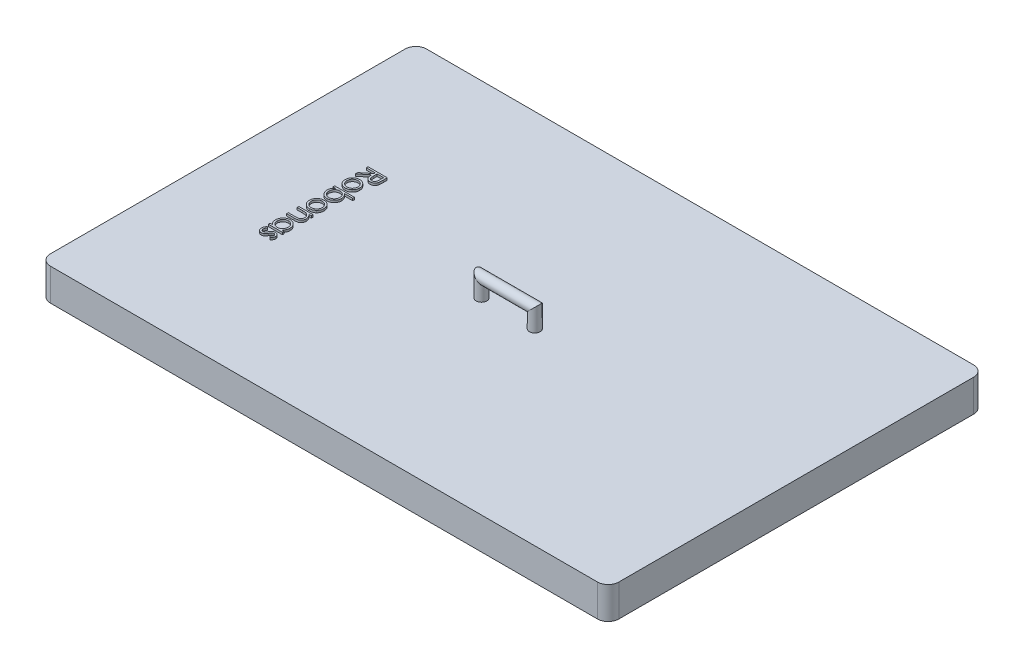
from build123d import *

# Parameters (mm, degrees)
SKETCH1_W           = 266
SKETCH1_H           = 176
BOSS_EXTRUDE2_DEPTH = 15
SKETCH1_4_W         = 256
SKETCH1_4_H         = 169.383458646
CUT_EXTRUDE2_DEPTH  = 10
FILLET1_R           = 5
SKETCH3_R           = 2.5
BOSS_EXTRUDE4_DEPTH = 1


with BuildPart() as part:
    # Sketch1 → Boss-Extrude2 (new body)
    with BuildSketch(Plane(origin=(0, 0, 0), x_dir=(1, 0, 0), z_dir=(0, 1, 0))):
        Rectangle(SKETCH1_W, SKETCH1_H)
    extrude(amount=BOSS_EXTRUDE2_DEPTH)

    # Sketch1_4 → Cut-Extrude2 (cut)
    with BuildSketch(Plane(origin=(0, 0, 0), x_dir=(1, 0, 0), z_dir=(0, 1, 0))):
        Rectangle(SKETCH1_4_W, SKETCH1_4_H)
    extrude(amount=CUT_EXTRUDE2_DEPTH, mode=Mode.SUBTRACT)

    # Fillet1
    fillet1_edges = [part.edges().sort_by_distance(p)[0] for p in [
        (-133, 7.5, -88),
        (133, 7.5, -88),
        (-133, 7.5, 88),
        (133, 7.5, 88),
        (128, 5, -84.691729323),
        (128, 5, 84.691729323),
        (-128, 5, 84.691729323),
        (-128, 5, -84.691729323),
    ]]
    fillet(fillet1_edges, radius=FILLET1_R)

    # Sweep1: sweep along a path in Sketch2
    with BuildLine(Plane.XY) as sweep1_path:
        Line((-14.258436322, 15), (-14.258436322, 23.643706027))
        Line((-14.258436322, 23.643706027), (10.667561874, 23.643706027))
        Line((10.667561874, 23.643706027), (10.667561874, 15))
    # Sketch3 → Sweep1 (sweep)
    with BuildSketch(Plane(origin=(0, 15, 0), x_dir=(1, 0, 0), z_dir=(0, 1, 0))):
        with Locations((10.667561874, 0)):
            Circle(SKETCH3_R)
    sweep(path=sweep1_path.line, transition=Transition.RIGHT)

    # Sketch4 → Boss-Extrude4 (add)
    # profile 1 of 7: a face of its own
    with BuildSketch(Plane(origin=(0, 15, 0), x_dir=(1, 0, 0), z_dir=(0, 1, 0))):
        with BuildLine():
            Line((-84, 25.615384615), (-84, 23.814302885))
            add(Edge.make_bspline(
                [(-84, 23.814302885), (-84.000400078, 23.694111411), (-84.001168273, 23.463330469), (-84.005451663, 23.132713488), (-84.017728578, 22.832300952), (-84.028293507, 22.562249937), (-84.047558499, 22.322565396), (-84.065971591, 22.112512362), (-84.09007529, 21.933058283), (-84.112460664, 21.824426094), (-84.122596154, 21.775240385)],
                knots=[0, 0, 0, 0, 1.410062039, 2.707475311, 3.878576406, 4.937260626, 5.877586885, 6.699081471, 7.410979367, 8, 8, 8, 8], degree=3))
            add(Edge.make_bspline(
                [(-84.122596154, 21.775240385), (-84.138863133, 21.70939362), (-84.171050074, 21.579104781), (-84.239115823, 21.391535723), (-84.317753217, 21.212722526), (-84.410832652, 21.043336224), (-84.516730622, 20.883361104), (-84.636065851, 20.733036691), (-84.769446066, 20.593222433), (-84.9134653, 20.462842527), (-85.069380163, 20.344657339), (-85.234919398, 20.242383522), (-85.409047654, 20.154806965), (-85.592371311, 20.084891967), (-85.783340667, 20.028647494), (-85.983623245, 19.988976389), (-86.192323697, 19.965188625), (-86.334672494, 19.962766572), (-86.406850962, 19.961538462)],
                knots=[0, 0, 0, 0, 1.02737288, 2.032829108, 3.019628684, 3.985738875, 4.958353778, 5.924249254, 6.890702889, 7.883913451, 8.865824512, 9.85161466, 10.829249435, 11.81541824, 12.821369441, 13.843154991, 14.906364023, 16, 16, 16, 16], degree=3))
            add(Edge.make_bspline(
                [(-86.406850962, 19.961538462), (-86.52676994, 19.965315787), (-86.760762927, 19.972686328), (-87.100346123, 20.041409392), (-87.417125695, 20.153972579), (-87.710660795, 20.309108056), (-87.975384276, 20.506575574), (-88.207113118, 20.743886628), (-88.402818683, 21.019829287), (-88.53708995, 21.277919856), (-88.623485838, 21.5060117), (-88.684579464, 21.69434228), (-88.730985975, 21.899935102), (-88.77316301, 22.119840624), (-88.805347476, 22.35575742), (-88.828204564, 22.60721041), (-88.842901845, 22.874828493), (-88.845049181, 23.058273594), (-88.846153846, 23.152644231)],
                knots=[0, 0, 0, 0, 1.260402266, 2.459371274, 3.627181936, 4.786749125, 5.93865593, 7.087644312, 8.261344208, 9.485713728, 10.136162886, 10.825977872, 11.566646758, 12.35154167, 13.181268117, 14.0701832, 15.007234106, 16, 16, 16, 16], degree=3))
            Line((-88.846153846, 23.152644231), (-93, 19.846153846))
            Line((-93, 19.846153846), (-93, 20.844951923))
            Line((-93, 20.844951923), (-88.846153846, 24.151442308))
            Line((-88.846153846, 24.151442308), (-88.846153846, 24.807692308))
            Line((-88.846153846, 24.807692308), (-93, 24.807692308))
            Line((-93, 24.807692308), (-93, 25.615384615))
            Line((-93, 25.615384615), (-84, 25.615384615))
        make_face()
        with BuildLine():
            Line((-84.923076923, 24.807692308), (-87.923076923, 24.807692308))
            Line((-87.923076923, 24.807692308), (-87.935697115, 23.159855769))
            add(Edge.make_bspline(
                [(-87.935697115, 23.159855769), (-87.935731152, 23.082918527), (-87.935797125, 22.933792237), (-87.925527418, 22.718047667), (-87.913844589, 22.517167394), (-87.895974881, 22.331919696), (-87.872944858, 22.162222093), (-87.844137589, 22.008158503), (-87.810573822, 21.869480373), (-87.758632346, 21.70773404), (-87.67629356, 21.527174715), (-87.556701165, 21.330702032), (-87.4053067, 21.163957301), (-87.234940904, 21.020191024), (-87.043774766, 20.909454374), (-86.840293432, 20.828857522), (-86.626253623, 20.778278506), (-86.47924031, 20.772265376), (-86.405048077, 20.769230769)],
                knots=[0, 0, 0, 0, 1.14660753, 2.222451964, 3.218720504, 4.145691244, 4.995719623, 5.770487122, 6.480909919, 7.121111896, 8.299844659, 9.430703709, 10.534634535, 11.641396424, 12.741395289, 13.810956493, 14.895269934, 16, 16, 16, 16], degree=3))
            add(Edge.make_bspline(
                [(-86.405048077, 20.769230769), (-86.332651102, 20.772274704), (-86.189186714, 20.778306672), (-85.979735021, 20.828955521), (-85.780637377, 20.910746007), (-85.595688717, 21.025435198), (-85.426406452, 21.164019494), (-85.283566379, 21.328608954), (-85.163946144, 21.510914648), (-85.088062918, 21.681426648), (-85.041446647, 21.833727621), (-85.008683654, 21.965981609), (-84.982139186, 22.115985304), (-84.961501364, 22.283379214), (-84.942929682, 22.467860496), (-84.930888296, 22.669934296), (-84.92361048, 22.889367263), (-84.923258914, 23.041460017), (-84.923076923, 23.120192308)],
                knots=[0, 0, 0, 0, 1.100801541, 2.181386982, 3.260112282, 4.364594493, 5.481957178, 6.577424609, 7.668452592, 8.790448866, 9.403819393, 10.091598921, 10.863153553, 11.720938239, 12.658472417, 13.685008818, 14.801622349, 16, 16, 16, 16], degree=3))
            Line((-84.923076923, 23.120192308), (-84.923076923, 24.807692308))
        make_face(mode=Mode.SUBTRACT)
    # profile 2 of 7: a face of its own
    with BuildSketch(Plane(origin=(0, 15, 0), x_dir=(1, 0, 0), z_dir=(0, 1, 0))):
        with BuildLine():
            add(Edge.make_bspline(
                [(-86.307692308, 15.054086538), (-86.310312316, 14.930677345), (-86.315449513, 14.688702076), (-86.370625766, 14.334382321), (-86.45429703, 13.996512736), (-86.57207522, 13.673643963), (-86.726604804, 13.368446779), (-86.913477056, 13.078196273), (-87.133956269, 12.803473977), (-87.304605669, 12.638850196), (-87.391225962, 12.555288462)],
                knots=[0, 0, 0, 0, 1.054042676, 2.066720093, 3.05716247, 4.025731183, 4.997454851, 5.974904663, 6.97207755, 8, 8, 8, 8], degree=3))
            add(Edge.make_bspline(
                [(-87.391225962, 12.555288462), (-87.474061925, 12.483334865), (-87.638130748, 12.340820173), (-87.904159467, 12.158079754), (-88.179662583, 12.000652885), (-88.468298566, 11.874490985), (-88.76754772, 11.77501521), (-89.078438606, 11.704389134), (-89.400284641, 11.662379872), (-89.618865939, 11.6567151), (-89.729567308, 11.653846154)],
                knots=[0, 0, 0, 0, 1.025258237, 2.030674902, 3.01204498, 3.988269485, 4.97094183, 5.956517959, 6.965070386, 8, 8, 8, 8], degree=3))
            add(Edge.make_bspline(
                [(-89.729567308, 11.653846154), (-89.840910313, 11.656369593), (-90.060929285, 11.661356025), (-90.38497908, 11.708525326), (-90.699194348, 11.781890971), (-91.002259526, 11.886887142), (-91.295101212, 12.021522221), (-91.576439558, 12.185812785), (-91.846832662, 12.380910367), (-92.103972868, 12.602066842), (-92.340999224, 12.846473491), (-92.547457975, 13.111674427), (-92.725083307, 13.392650259), (-92.86616721, 13.693236584), (-92.979890661, 14.009154651), (-93.0583103, 14.342413897), (-93.106148408, 14.692717027), (-93.112262572, 14.931935629), (-93.115384615, 15.054086538)],
                knots=[0, 0, 0, 0, 0.998669827, 1.973418153, 2.932281609, 3.89081133, 4.846438734, 5.82045571, 6.809776312, 7.834649874, 8.860672198, 9.859676908, 10.845817165, 11.837296335, 12.833502054, 13.853824644, 14.904110009, 16, 16, 16, 16], degree=3))
            add(Edge.make_bspline(
                [(-93.115384615, 15.054086538), (-93.112236741, 15.17683004), (-93.106071469, 15.417229389), (-93.058666147, 15.768851558), (-92.97905278, 16.10351393), (-92.867575081, 16.420926363), (-92.723924488, 16.721511469), (-92.548149099, 17.003524808), (-92.340894678, 17.268850834), (-92.104001195, 17.513334109), (-91.846825363, 17.73447004), (-91.576441452, 17.929572923), (-91.295100718, 18.093862109), (-91.002259657, 18.228497549), (-90.699194313, 18.333493624), (-90.38497909, 18.406859295), (-90.060929283, 18.454028589), (-89.840910312, 18.459015022), (-89.729567308, 18.461538462)],
                knots=[0, 0, 0, 0, 1.099861214, 2.154133753, 3.1731438, 4.178222029, 5.163564916, 6.153006591, 7.15072618, 8.175428628, 9.198983792, 10.187031731, 11.15979573, 12.114193814, 13.071490482, 14.029120454, 15.002614863, 16, 16, 16, 16], degree=3))
            add(Edge.make_bspline(
                [(-89.729567308, 18.461538462), (-89.619467618, 18.458649949), (-89.401489155, 18.452931191), (-89.080248142, 18.410964168), (-88.769883427, 18.340613594), (-88.471789346, 18.241018575), (-88.184418225, 18.113693798), (-87.908234374, 17.958479058), (-87.643408601, 17.773874574), (-87.479551824, 17.631926699), (-87.396634615, 17.560096154)],
                knots=[0, 0, 0, 0, 1.031353054, 2.041901799, 3.029428768, 4.008703097, 4.981709435, 5.96992636, 6.972712378, 8, 8, 8, 8], degree=3))
            add(Edge.make_bspline(
                [(-87.396634615, 17.560096154), (-87.309277722, 17.476653482), (-87.137475019, 17.312548786), (-86.917430822, 17.036558333), (-86.728039083, 16.747556385), (-86.573587268, 16.440390574), (-86.454510729, 16.116624041), (-86.370235247, 15.776243341), (-86.315693572, 15.420633933), (-86.310385976, 15.17748666), (-86.307692308, 15.054086538)],
                knots=[0, 0, 0, 0, 1.027951202, 2.021646915, 2.998468564, 3.9668038, 4.943370589, 5.93035926, 6.949632805, 8, 8, 8, 8], degree=3))
        make_face()
        with BuildLine():
            add(Edge.make_bspline(
                [(-87.115384615, 15.057692308), (-87.117865128, 15.144960353), (-87.122762119, 15.317243633), (-87.160004511, 15.570838265), (-87.219019534, 15.814964861), (-87.302832154, 16.050117738), (-87.411186056, 16.275387406), (-87.543521406, 16.491021727), (-87.700543034, 16.696441367), (-87.879129987, 16.890068263), (-88.073106737, 17.069855859), (-88.281691003, 17.225206495), (-88.49889891, 17.357547932), (-88.725857929, 17.4676806), (-88.964717468, 17.549735125), (-89.212812329, 17.609320871), (-89.470637197, 17.646530608), (-89.645908454, 17.651381221), (-89.734975962, 17.653846154)],
                knots=[0, 0, 0, 0, 1.021589593, 2.016807015, 2.994807536, 3.958602519, 4.934347097, 5.916793557, 6.916107818, 7.957073844, 8.998039869, 10.008589932, 10.997041759, 11.972786337, 12.956492182, 13.948170289, 14.957322718, 16, 16, 16, 16], degree=3))
            add(Edge.make_bspline(
                [(-89.734975962, 17.653846154), (-89.850057688, 17.649725225), (-90.078473396, 17.641545951), (-90.414770075, 17.574695016), (-90.738231289, 17.463652497), (-91.044962481, 17.310532301), (-91.329253269, 17.121960174), (-91.584888887, 16.901463746), (-91.802010999, 16.645994577), (-91.984614351, 16.364251882), (-92.12841432, 16.060228314), (-92.231538019, 15.739020958), (-92.297672127, 15.403554503), (-92.304323016, 15.173988685), (-92.307692308, 15.057692308)],
                knots=[0, 0, 0, 0, 1.016977094, 2.018509362, 3.018404954, 4.033172147, 5.041280572, 6.028085189, 7.007940189, 7.995502847, 8.989109012, 9.972200833, 10.97273166, 12, 12, 12, 12], degree=3))
            add(Edge.make_bspline(
                [(-92.307692308, 15.057692308), (-92.304342533, 14.941389241), (-92.29773017, 14.711810218), (-92.231202961, 14.375877005), (-92.128862738, 14.053789322), (-91.984451938, 13.749449647), (-91.802701192, 13.467578647), (-91.583651962, 13.213933703), (-91.329925288, 12.991538389), (-91.04533943, 12.802779541), (-90.737754438, 12.652126536), (-90.414829675, 12.540561816), (-90.078458217, 12.473871208), (-89.850052603, 12.465670294), (-89.734975962, 12.461538462)],
                knots=[0, 0, 0, 0, 1.027082318, 2.027431966, 3.015401697, 4.008827937, 4.996211763, 5.971861488, 6.96198607, 7.969911943, 8.982141629, 9.981856156, 10.983207064, 12, 12, 12, 12], degree=3))
            add(Edge.make_bspline(
                [(-89.734975962, 12.461538462), (-89.645901342, 12.463985054), (-89.47061609, 12.468799576), (-89.212893014, 12.506271823), (-88.96422677, 12.564931961), (-88.726820518, 12.650579676), (-88.49779043, 12.756932527), (-88.282343243, 12.892493322), (-88.072974138, 13.047120367), (-87.879246904, 13.227237869), (-87.699890518, 13.420842965), (-87.544093401, 13.627805831), (-87.411110485, 13.843540298), (-87.30281881, 14.068881158), (-87.219342131, 14.303501896), (-87.159747432, 14.546887309), (-87.122897909, 14.799358904), (-87.117905064, 14.971030421), (-87.115384615, 15.057692308)],
                knots=[0, 0, 0, 0, 1.043020522, 2.052505155, 3.044509714, 4.030878336, 5.003918577, 5.996372628, 7.007255355, 8.048564058, 9.08987276, 10.095126797, 11.077896669, 12.053962454, 13.01807471, 13.98956039, 14.985105429, 16, 16, 16, 16], degree=3))
        make_face(mode=Mode.SUBTRACT)
    # profile 3 of 7: a face of its own
    with BuildSketch(Plane(origin=(0, 15, 0), x_dir=(1, 0, 0), z_dir=(0, 1, 0))):
        with BuildLine():
            Line((-93, 10.038461538), (-83.769230769, 10.038461538))
            Line((-83.769230769, 10.038461538), (-83.769230769, 9.230769231))
            Line((-83.769230769, 9.230769231), (-87.616586538, 9.230769231))
            add(Edge.make_bspline(
                [(-87.616586538, 9.230769231), (-87.511565591, 9.14055883), (-87.306035054, 8.964013173), (-87.041638365, 8.664576056), (-86.812532085, 8.353748728), (-86.628333438, 8.023877242), (-86.484150291, 7.677854951), (-86.381749418, 7.316051007), (-86.318088663, 6.937345855), (-86.311198001, 6.679340003), (-86.307692308, 6.548076923)],
                knots=[0, 0, 0, 0, 1.073845349, 2.101561798, 3.093746447, 4.06731023, 5.027507813, 5.99794647, 6.981435071, 8, 8, 8, 8], degree=3))
            add(Edge.make_bspline(
                [(-86.307692308, 6.548076923), (-86.310874268, 6.431932707), (-86.317165545, 6.202295798), (-86.365186826, 5.864752417), (-86.442375726, 5.540354965), (-86.551412171, 5.229033099), (-86.692883108, 4.930954836), (-86.864644861, 4.645078234), (-87.068295232, 4.372771858), (-87.301299405, 4.118090849), (-87.554177383, 3.883262376), (-87.824755781, 3.67802318), (-88.108202711, 3.503682347), (-88.40638236, 3.363434969), (-88.715630694, 3.24899862), (-89.040375561, 3.17339941), (-89.377722514, 3.124564577), (-89.607397299, 3.11847859), (-89.724158654, 3.115384615)],
                knots=[0, 0, 0, 0, 1.034424137, 2.045232812, 3.030843571, 4.001080581, 4.978206309, 5.965255608, 6.967506581, 8.002193933, 9.036548792, 10.037741014, 11.022988172, 11.995276286, 12.96911093, 13.954721688, 14.960227752, 16, 16, 16, 16], degree=3))
            add(Edge.make_bspline(
                [(-89.724158654, 3.115384615), (-89.839101557, 3.118564034), (-90.065750859, 3.124833346), (-90.399282004, 3.17271671), (-90.720295801, 3.251778533), (-91.027962749, 3.364821576), (-91.32372824, 3.506931419), (-91.604220708, 3.684646128), (-91.874320931, 3.889874412), (-92.125353126, 4.127297365), (-92.357381869, 4.38421793), (-92.558996951, 4.659140269), (-92.733126688, 4.945139496), (-92.871097839, 5.246673213), (-92.982700208, 5.559276748), (-93.060145699, 5.886299171), (-93.105333555, 6.225890329), (-93.11200787, 6.456596042), (-93.115384615, 6.573317308)],
                knots=[0, 0, 0, 0, 1.024244038, 2.01964794, 2.996620209, 3.965911562, 4.936179293, 5.91563013, 6.920572822, 7.955171681, 8.990768464, 10.002129126, 10.989675881, 11.969873457, 12.952483066, 13.943799762, 14.959703725, 16, 16, 16, 16], degree=3))
            add(Edge.make_bspline(
                [(-93.115384615, 6.573317308), (-93.111685864, 6.706943972), (-93.104433259, 6.968962561), (-93.044132873, 7.352211302), (-92.942075532, 7.7145635), (-92.803561892, 8.060093369), (-92.616958176, 8.384927793), (-92.386781385, 8.692266027), (-92.10612044, 8.976983158), (-91.892587031, 9.144724562), (-91.783052885, 9.230769231)],
                knots=[0, 0, 0, 0, 1.035884751, 2.031189381, 2.999123778, 3.950239786, 4.910390163, 5.895605504, 6.920529319, 8, 8, 8, 8], degree=3))
            Line((-91.783052885, 9.230769231), (-93, 9.230769231))
            Line((-93, 9.230769231), (-93, 10.038461538))
        make_face()
        with BuildLine():
            add(Edge.make_bspline(
                [(-92.307692308, 6.580528846), (-92.303491502, 6.462463439), (-92.29519978, 6.229421106), (-92.230468265, 5.887307473), (-92.122763785, 5.559931944), (-91.97547212, 5.248920902), (-91.790238118, 4.959228033), (-91.566275507, 4.7002075), (-91.309682789, 4.470641403), (-91.022814178, 4.275838035), (-90.713961589, 4.118571955), (-90.391528611, 4.007794306), (-90.061005568, 3.934142726), (-89.836930175, 3.926781595), (-89.724158654, 3.923076923)],
                knots=[0, 0, 0, 0, 1.031861621, 2.036730714, 3.032102247, 4.038124785, 5.038035477, 6.029195352, 7.02284546, 8.040167683, 9.05302878, 10.043491941, 11.015338596, 12, 12, 12, 12], degree=3))
            add(Edge.make_bspline(
                [(-89.724158654, 3.923076923), (-89.611474992, 3.927886568), (-89.38655753, 3.937486655), (-89.053598118, 4.005934516), (-88.729956016, 4.121664762), (-88.418136822, 4.279110017), (-88.128630504, 4.476310745), (-87.867035107, 4.704889798), (-87.64197827, 4.967008534), (-87.45426317, 5.25708886), (-87.301117069, 5.566133526), (-87.196085154, 5.891392555), (-87.127330298, 6.22608555), (-87.11938676, 6.453388154), (-87.115384615, 6.567908654)],
                knots=[0, 0, 0, 0, 0.984698701, 1.96546623, 2.957354799, 3.98164001, 5.010280354, 6.011473015, 7.009725998, 8.019440419, 9.024964737, 10.015029379, 10.999924227, 12, 12, 12, 12], degree=3))
            add(Edge.make_bspline(
                [(-87.115384615, 6.567908654), (-87.119384624, 6.684824927), (-87.127323829, 6.916880004), (-87.196204475, 7.25931516), (-87.301764451, 7.593753649), (-87.453267947, 7.913388158), (-87.638823242, 8.211159027), (-87.856018982, 8.477775244), (-88.106158849, 8.705448988), (-88.384365932, 8.894973668), (-88.686237005, 9.04436577), (-89.006900708, 9.154717045), (-89.347247902, 9.218277087), (-89.580268452, 9.226554515), (-89.698918269, 9.230769231)],
                knots=[0, 0, 0, 0, 1.0169775, 2.018493981, 3.029491472, 4.064042901, 5.08895728, 6.077764832, 7.048099865, 8.023317454, 8.999054219, 9.971953187, 10.967355531, 12, 12, 12, 12], degree=3))
            add(Edge.make_bspline(
                [(-89.698918269, 9.230769231), (-89.78978698, 9.228301546), (-89.968645359, 9.223444361), (-90.23125892, 9.186337141), (-90.48257442, 9.127310338), (-90.722854875, 9.044133924), (-90.950776258, 8.93487266), (-91.16795834, 8.803085007), (-91.373335029, 8.646500316), (-91.563835212, 8.467460516), (-91.738064869, 8.272292486), (-91.891039262, 8.063841521), (-92.018895683, 7.843445365), (-92.124292367, 7.612128556), (-92.208310503, 7.370412697), (-92.264325741, 7.116166409), (-92.302797937, 6.852136788), (-92.306043673, 6.672018076), (-92.307692308, 6.580528846)],
                knots=[0, 0, 0, 0, 1.050410851, 2.067540964, 3.060285716, 4.031641603, 5.001405429, 5.977447716, 6.964216063, 7.981915705, 8.995836261, 9.985438752, 10.966317358, 11.93650433, 12.920994585, 13.918930257, 14.942944538, 16, 16, 16, 16], degree=3))
        make_face(mode=Mode.SUBTRACT)
    # profile 4 of 7: a face of its own
    with BuildSketch(Plane(origin=(0, 15, 0), x_dir=(1, 0, 0), z_dir=(0, 1, 0))):
        with BuildLine():
            add(Edge.make_bspline(
                [(-86.307692308, -1.676682692), (-86.310312316, -1.800091886), (-86.315449513, -2.042067155), (-86.370625766, -2.39638691), (-86.45429703, -2.734256495), (-86.57207522, -3.057125267), (-86.726604804, -3.362322452), (-86.913477056, -3.652572958), (-87.133956269, -3.927295254), (-87.304605669, -4.091919034), (-87.391225962, -4.175480769)],
                knots=[0, 0, 0, 0, 1.054042676, 2.066720093, 3.05716247, 4.025731183, 4.997454851, 5.974904663, 6.97207755, 8, 8, 8, 8], degree=3))
            add(Edge.make_bspline(
                [(-87.391225962, -4.175480769), (-87.474061925, -4.247434365), (-87.638130748, -4.389949057), (-87.904159467, -4.572689477), (-88.179662583, -4.730116346), (-88.468298566, -4.856278246), (-88.76754772, -4.955754021), (-89.078438606, -5.026380097), (-89.400284641, -5.068389358), (-89.618865939, -5.074054131), (-89.729567308, -5.076923077)],
                knots=[0, 0, 0, 0, 1.025258237, 2.030674902, 3.01204498, 3.988269485, 4.97094183, 5.956517959, 6.965070386, 8, 8, 8, 8], degree=3))
            add(Edge.make_bspline(
                [(-89.729567308, -5.076923077), (-89.840910313, -5.074399638), (-90.060929285, -5.069413206), (-90.38497908, -5.022243905), (-90.699194348, -4.94887826), (-91.002259526, -4.843882089), (-91.295101212, -4.709247009), (-91.576439558, -4.544956446), (-91.846832662, -4.349858864), (-92.103972868, -4.128702389), (-92.340999224, -3.884295739), (-92.547457975, -3.619094803), (-92.725083307, -3.338118972), (-92.86616721, -3.037532647), (-92.979890661, -2.72161458), (-93.0583103, -2.388355334), (-93.106148408, -2.038052203), (-93.112262572, -1.798833602), (-93.115384615, -1.676682692)],
                knots=[0, 0, 0, 0, 0.998669827, 1.973418153, 2.932281609, 3.89081133, 4.846438734, 5.82045571, 6.809776312, 7.834649874, 8.860672198, 9.859676908, 10.845817165, 11.837296335, 12.833502054, 13.853824644, 14.904110009, 16, 16, 16, 16], degree=3))
            add(Edge.make_bspline(
                [(-93.115384615, -1.676682692), (-93.112236741, -1.553939191), (-93.106071469, -1.313539842), (-93.058666147, -0.961917672), (-92.97905278, -0.627255301), (-92.867575081, -0.309842868), (-92.723924488, -0.009257762), (-92.548149099, 0.272755577), (-92.340894678, 0.538081603), (-92.104001195, 0.782564879), (-91.846825363, 1.003700809), (-91.576441452, 1.198803692), (-91.295100718, 1.363092879), (-91.002259657, 1.497728319), (-90.699194313, 1.602724393), (-90.38497909, 1.676090064), (-90.060929283, 1.723259358), (-89.840910312, 1.728245792), (-89.729567308, 1.730769231)],
                knots=[0, 0, 0, 0, 1.099861214, 2.154133753, 3.1731438, 4.178222029, 5.163564916, 6.153006591, 7.15072618, 8.175428628, 9.198983792, 10.187031731, 11.15979573, 12.114193814, 13.071490482, 14.029120454, 15.002614863, 16, 16, 16, 16], degree=3))
            add(Edge.make_bspline(
                [(-89.729567308, 1.730769231), (-89.619467618, 1.727880718), (-89.401489155, 1.72216196), (-89.080248142, 1.680194937), (-88.769883427, 1.609844363), (-88.471789346, 1.510249344), (-88.184418225, 1.382924567), (-87.908234374, 1.227709827), (-87.643408601, 1.043105343), (-87.479551824, 0.901157468), (-87.396634615, 0.829326923)],
                knots=[0, 0, 0, 0, 1.031353054, 2.041901799, 3.029428768, 4.008703097, 4.981709435, 5.96992636, 6.972712378, 8, 8, 8, 8], degree=3))
            add(Edge.make_bspline(
                [(-87.396634615, 0.829326923), (-87.309277722, 0.745884252), (-87.137475019, 0.581779556), (-86.917430822, 0.305789102), (-86.728039083, 0.016787154), (-86.573587268, -0.290378657), (-86.454510729, -0.61414519), (-86.370235247, -0.954525889), (-86.315693572, -1.310135297), (-86.310385976, -1.553282571), (-86.307692308, -1.676682692)],
                knots=[0, 0, 0, 0, 1.027951202, 2.021646915, 2.998468564, 3.9668038, 4.943370589, 5.93035926, 6.949632805, 8, 8, 8, 8], degree=3))
        make_face()
        with BuildLine():
            add(Edge.make_bspline(
                [(-87.115384615, -1.673076923), (-87.117865128, -1.585808878), (-87.122762119, -1.413525597), (-87.160004511, -1.159930966), (-87.219019534, -0.91580437), (-87.302832154, -0.680651493), (-87.411186056, -0.455381824), (-87.543521406, -0.239747504), (-87.700543034, -0.034327863), (-87.879129987, 0.159299032), (-88.073106737, 0.339086628), (-88.281691003, 0.494437264), (-88.49889891, 0.626778701), (-88.725857929, 0.73691137), (-88.964717468, 0.818965895), (-89.212812329, 0.87855164), (-89.470637197, 0.915761377), (-89.645908454, 0.92061199), (-89.734975962, 0.923076923)],
                knots=[0, 0, 0, 0, 1.021589593, 2.016807015, 2.994807536, 3.958602519, 4.934347097, 5.916793557, 6.916107818, 7.957073844, 8.998039869, 10.008589932, 10.997041759, 11.972786337, 12.956492182, 13.948170289, 14.957322718, 16, 16, 16, 16], degree=3))
            add(Edge.make_bspline(
                [(-89.734975962, 0.923076923), (-89.850057688, 0.918955994), (-90.078473396, 0.91077672), (-90.414770075, 0.843925785), (-90.738231289, 0.732883266), (-91.044962481, 0.57976307), (-91.329253269, 0.391190944), (-91.584888887, 0.170694515), (-91.802010999, -0.084774654), (-91.984614351, -0.366517349), (-92.12841432, -0.670540917), (-92.231538019, -0.991748273), (-92.297672127, -1.327214728), (-92.304323016, -1.556780546), (-92.307692308, -1.673076923)],
                knots=[0, 0, 0, 0, 1.016977094, 2.018509362, 3.018404954, 4.033172147, 5.041280572, 6.028085189, 7.007940189, 7.995502847, 8.989109012, 9.972200833, 10.97273166, 12, 12, 12, 12], degree=3))
            add(Edge.make_bspline(
                [(-92.307692308, -1.673076923), (-92.304342533, -1.78937999), (-92.29773017, -2.018959013), (-92.231202961, -2.354892226), (-92.128862738, -2.676979909), (-91.984451938, -2.981319583), (-91.802701192, -3.263190584), (-91.583651962, -3.516835528), (-91.329925288, -3.739230842), (-91.04533943, -3.92798969), (-90.737754438, -4.078642695), (-90.414829675, -4.190207415), (-90.078458217, -4.256898023), (-89.850052603, -4.265098937), (-89.734975962, -4.269230769)],
                knots=[0, 0, 0, 0, 1.027082318, 2.027431966, 3.015401697, 4.008827937, 4.996211763, 5.971861488, 6.96198607, 7.969911943, 8.982141629, 9.981856156, 10.983207064, 12, 12, 12, 12], degree=3))
            add(Edge.make_bspline(
                [(-89.734975962, -4.269230769), (-89.645901342, -4.266784176), (-89.47061609, -4.261969655), (-89.212893014, -4.224497408), (-88.96422677, -4.16583727), (-88.726820518, -4.080189555), (-88.49779043, -3.973836704), (-88.282343243, -3.838275908), (-88.072974138, -3.683648864), (-87.879246904, -3.503531362), (-87.699890518, -3.309926266), (-87.544093401, -3.1029634), (-87.411110485, -2.887228932), (-87.30281881, -2.661888073), (-87.219342131, -2.427267335), (-87.159747432, -2.183881921), (-87.122897909, -1.931410327), (-87.117905064, -1.75973881), (-87.115384615, -1.673076923)],
                knots=[0, 0, 0, 0, 1.043020522, 2.052505155, 3.044509714, 4.030878336, 5.003918577, 5.996372628, 7.007255355, 8.048564058, 9.08987276, 10.095126797, 11.077896669, 12.053962454, 13.01807471, 13.98956039, 14.985105429, 16, 16, 16, 16], degree=3))
        make_face(mode=Mode.SUBTRACT)
    # profile 5 of 7: a face of its own
    with BuildSketch(Plane(origin=(0, 15, 0), x_dir=(1, 0, 0), z_dir=(0, 1, 0))):
        with BuildLine():
            Line((-86.423076923, -6.692307692), (-86.423076923, -7.5))
            Line((-86.423076923, -7.5), (-87.609375, -7.5))
            add(Edge.make_bspline(
                [(-87.609375, -7.5), (-87.501779427, -7.586239633), (-87.292986464, -7.75359065), (-87.018562129, -8.032293221), (-86.792417265, -8.326834679), (-86.612150366, -8.63541126), (-86.476259042, -8.958441857), (-86.378118076, -9.293957409), (-86.319271374, -9.643966653), (-86.31158221, -9.88198949), (-86.307692308, -10.002403846)],
                knots=[0, 0, 0, 0, 1.12780773, 2.188550248, 3.19190651, 4.159438251, 5.104880172, 6.052711206, 7.014878035, 8, 8, 8, 8], degree=3))
            add(Edge.make_bspline(
                [(-86.307692308, -10.002403846), (-86.31218663, -10.124107902), (-86.320983102, -10.362312097), (-86.390360482, -10.709187754), (-86.509549089, -11.033446574), (-86.671166142, -11.334378224), (-86.873229581, -11.605067369), (-87.109897835, -11.84064041), (-87.380037022, -12.037143557), (-87.631419505, -12.168697028), (-87.854319996, -12.255434036), (-88.045243386, -12.310028215), (-88.257946233, -12.356394592), (-88.491791188, -12.39659021), (-88.748415015, -12.423788591), (-89.026766251, -12.44524017), (-89.326754578, -12.460613963), (-89.534234478, -12.461223923), (-89.641225962, -12.461538462)],
                knots=[0, 0, 0, 0, 1.235764744, 2.418689688, 3.575570385, 4.733739044, 5.876600945, 6.994686206, 8.113221397, 9.257403329, 9.866223892, 10.540462211, 11.272173464, 12.077110251, 12.949508505, 13.892531187, 14.913238277, 16, 16, 16, 16], degree=3))
            Line((-89.641225962, -12.461538462), (-93, -12.461538462))
            Line((-93, -12.461538462), (-93, -11.653846154))
            Line((-93, -11.653846154), (-89.90625, -11.653846154))
            add(Edge.make_bspline(
                [(-89.90625, -11.653846154), (-89.81670657, -11.653349333), (-89.645425228, -11.652399), (-89.400190597, -11.649401623), (-89.177796538, -11.642176406), (-88.978774736, -11.632023601), (-88.8033163, -11.617163237), (-88.651063874, -11.601676471), (-88.522210765, -11.582737959), (-88.44464341, -11.565861896), (-88.409855769, -11.558293269)],
                knots=[0, 0, 0, 0, 1.430800155, 2.736877192, 3.918605307, 4.986035426, 5.920637409, 6.731861385, 7.431261377, 8, 8, 8, 8], degree=3))
            add(Edge.make_bspline(
                [(-88.409855769, -11.558293269), (-88.307741294, -11.530970474), (-88.111202522, -11.478382546), (-87.844611329, -11.348438018), (-87.617815989, -11.184344411), (-87.432218705, -10.984035655), (-87.287779411, -10.749446604), (-87.18756067, -10.481228236), (-87.124878835, -10.181968875), (-87.118637638, -9.971486176), (-87.115384615, -9.861778846)],
                knots=[0, 0, 0, 0, 1.084156227, 2.086665306, 3.027808233, 3.945421172, 4.874247719, 5.839848303, 6.874090471, 8, 8, 8, 8], degree=3))
            add(Edge.make_bspline(
                [(-87.115384615, -9.861778846), (-87.116608172, -9.796804575), (-87.119029558, -9.668222171), (-87.143339541, -9.477554133), (-87.183064972, -9.292593837), (-87.236818931, -9.1115591), (-87.309966738, -8.938290147), (-87.39463632, -8.767723606), (-87.498317192, -8.60474078), (-87.614493028, -8.446259097), (-87.74396794, -8.298989976), (-87.878587907, -8.159996659), (-88.024020466, -8.037876023), (-88.175115725, -7.927024027), (-88.334910949, -7.831450252), (-88.501697475, -7.747992094), (-88.675739267, -7.677187991), (-88.796532016, -7.64200366), (-88.856971154, -7.624399038)],
                knots=[0, 0, 0, 0, 1.02388931, 2.02625049, 3.024079426, 4.004119353, 4.998163158, 5.985366248, 7.002659681, 8.039138713, 9.080111048, 10.09169763, 11.086418407, 12.069932368, 13.043171485, 14.017654831, 15.008125612, 16, 16, 16, 16], degree=3))
            add(Edge.make_bspline(
                [(-88.856971154, -7.624399038), (-88.901341676, -7.614268514), (-88.997933982, -7.592214891), (-89.156448203, -7.568395285), (-89.33981671, -7.546775806), (-89.547825525, -7.528680769), (-89.781202918, -7.517609698), (-90.038952216, -7.505538392), (-90.322101186, -7.501143664), (-90.519231253, -7.500391897), (-90.621995192, -7.5)],
                knots=[0, 0, 0, 0, 0.615963638, 1.340920617, 2.168419149, 3.115676021, 4.16674242, 5.331190069, 6.6087489, 8, 8, 8, 8], degree=3))
            Line((-90.621995192, -7.5), (-93, -7.5))
            Line((-93, -7.5), (-93, -6.692307692))
            Line((-93, -6.692307692), (-86.423076923, -6.692307692))
        make_face()
    # profile 6 of 7: a face of its own
    with BuildSketch(Plane(origin=(0, 15, 0), x_dir=(1, 0, 0), z_dir=(0, 1, 0))):
        with BuildLine():
            Line((-86.423076923, -21), (-93, -21))
            Line((-93, -21), (-93, -20.192307692))
            Line((-93, -20.192307692), (-91.862379808, -20.192307692))
            add(Edge.make_bspline(
                [(-91.862379808, -20.192307692), (-91.965366553, -20.101249847), (-92.166346482, -19.923549316), (-92.428127588, -19.626806496), (-92.646290556, -19.313567622), (-92.820856663, -18.982773465), (-92.95298278, -18.63541375), (-93.045897696, -18.272479061), (-93.106382769, -17.8944531), (-93.11235708, -17.636652431), (-93.115384615, -17.506009615)],
                knots=[0, 0, 0, 0, 1.074295371, 2.096500925, 3.086030275, 4.053105238, 5.014108356, 5.985331429, 6.979048527, 8, 8, 8, 8], degree=3))
            add(Edge.make_bspline(
                [(-93.115384615, -17.506009615), (-93.11223161, -17.389863133), (-93.106013744, -17.160817126), (-93.057760295, -16.823889752), (-92.980309339, -16.499635781), (-92.872461929, -16.18784856), (-92.730144207, -15.890640702), (-92.557920105, -15.606337521), (-92.354837468, -15.334275502), (-92.12176669, -15.079628697), (-91.868886425, -14.844838033), (-91.598381295, -14.639419916), (-91.313966682, -14.465321373), (-91.015722522, -14.322243552), (-90.703866831, -14.211522432), (-90.378613549, -14.134490491), (-90.040503879, -14.086289041), (-89.810258409, -14.080074325), (-89.693509615, -14.076923077)],
                knots=[0, 0, 0, 0, 1.034036272, 2.039165313, 3.024406509, 3.999331371, 4.971254918, 5.953351348, 6.95522652, 7.989525907, 9.023492927, 10.024309745, 11.009187477, 11.988246066, 12.964946762, 13.950187958, 14.960617622, 16, 16, 16, 16], degree=3))
            add(Edge.make_bspline(
                [(-89.693509615, -14.076923077), (-89.57917389, -14.080144219), (-89.35313833, -14.086512242), (-89.020714435, -14.13397472), (-88.700498621, -14.213726872), (-88.393677087, -14.325862164), (-88.099014162, -14.469016069), (-87.818815292, -14.646108712), (-87.548794224, -14.851452807), (-87.297610055, -15.08875279), (-87.066430209, -15.345685143), (-86.86285404, -15.619269321), (-86.691071506, -15.906094004), (-86.551429007, -16.206734315), (-86.440460576, -16.519061455), (-86.363104894, -16.845448006), (-86.317632137, -17.184409694), (-86.31103742, -17.414525684), (-86.307692308, -17.53125)],
                knots=[0, 0, 0, 0, 1.02050356, 2.017480486, 2.990790918, 3.96161403, 4.928589988, 5.909588639, 6.91611943, 7.952353252, 8.989586576, 9.99823133, 10.991940466, 11.968822692, 12.952985106, 13.945868367, 14.958059758, 16, 16, 16, 16], degree=3))
            add(Edge.make_bspline(
                [(-86.307692308, -17.53125), (-86.311371382, -17.665483434), (-86.318585872, -17.928708863), (-86.379263405, -18.31422357), (-86.480513657, -18.679258838), (-86.619668516, -19.025918778), (-86.803214933, -19.352858613), (-87.036841063, -19.656054583), (-87.315209721, -19.941610515), (-87.529647491, -20.107117208), (-87.640024038, -20.192307692)],
                knots=[0, 0, 0, 0, 1.03879612, 2.037030165, 3.012306674, 3.966139504, 4.922386257, 5.905048148, 6.921675258, 8, 8, 8, 8], degree=3))
            Line((-87.640024038, -20.192307692), (-86.423076923, -20.192307692))
            Line((-86.423076923, -20.192307692), (-86.423076923, -21))
        make_face()
        with BuildLine():
            add(Edge.make_bspline(
                [(-87.115384615, -17.542067308), (-87.119585353, -17.424001796), (-87.127876941, -17.190959256), (-87.192609439, -16.848847136), (-87.300310225, -16.521465923), (-87.447615783, -16.210476258), (-87.632798266, -15.920704122), (-87.856951424, -15.66197676), (-88.112947113, -15.431198768), (-88.402937611, -15.240395503), (-88.710276168, -15.07952937), (-89.033988106, -14.969215141), (-89.365092714, -14.895808473), (-89.589754066, -14.888356129), (-89.702524038, -14.884615385)],
                knots=[0, 0, 0, 0, 1.031093775, 2.03521511, 3.029845951, 4.035119871, 5.034286494, 6.024708811, 7.017619509, 8.03559408, 9.050082311, 10.039808432, 11.016071318, 12, 12, 12, 12], degree=3))
            add(Edge.make_bspline(
                [(-89.702524038, -14.884615385), (-89.814597878, -14.88945503), (-90.038306264, -14.899115351), (-90.370394629, -14.967280194), (-90.69280339, -15.085386759), (-91.004399259, -15.242581106), (-91.294984998, -15.437664235), (-91.555986654, -15.666526921), (-91.781038762, -15.92855353), (-91.969407446, -16.218954206), (-92.121035282, -16.528644657), (-92.227954644, -16.854474592), (-92.295468464, -17.190719078), (-92.303603987, -17.419757676), (-92.307692308, -17.534855769)],
                knots=[0, 0, 0, 0, 0.979154363, 1.954470772, 2.947816011, 3.971783346, 4.997163654, 5.998045606, 6.995988793, 8.00538986, 9.015323546, 10.000094788, 10.994993517, 12, 12, 12, 12], degree=3))
            add(Edge.make_bspline(
                [(-92.307692308, -17.534855769), (-92.303487754, -17.651732091), (-92.295146583, -17.883596301), (-92.229331508, -18.226513633), (-92.122969838, -18.559809176), (-91.973555926, -18.878525052), (-91.789229684, -19.175212497), (-91.572486793, -19.44115506), (-91.322528266, -19.668239979), (-91.045612839, -19.858608631), (-90.743457317, -20.008990323), (-90.420383554, -20.115056477), (-90.078930444, -20.180200911), (-89.845244676, -20.188216298), (-89.725961538, -20.192307692)],
                knots=[0, 0, 0, 0, 1.017484689, 2.018529338, 3.030031036, 4.058138743, 5.076350332, 6.065651025, 7.036469986, 8.00785331, 8.984076697, 9.96571663, 10.961615403, 12, 12, 12, 12], degree=3))
            add(Edge.make_bspline(
                [(-89.725961538, -20.192307692), (-89.635092867, -20.189839965), (-89.456234564, -20.184982698), (-89.193620446, -20.147876077), (-88.942306985, -20.088847083), (-88.702019109, -20.005678642), (-88.47412532, -19.896387733), (-88.256839246, -19.764711805), (-88.05218488, -19.60794999), (-87.860421396, -19.43087295), (-87.686388798, -19.234860586), (-87.532997926, -19.026426841), (-87.40318704, -18.806096132), (-87.299304377, -18.574023118), (-87.214673777, -18.331995243), (-87.158776728, -18.077692714), (-87.120272288, -17.813678437), (-87.117030994, -17.633557611), (-87.115384615, -17.542067308)],
                knots=[0, 0, 0, 0, 1.050062701, 2.066855696, 3.059271411, 4.030305351, 4.999747758, 5.975466543, 6.961907836, 7.974539719, 8.98812422, 9.98710676, 10.961662635, 11.93785114, 12.922015094, 13.919620009, 14.94329489, 16, 16, 16, 16], degree=3))
        make_face(mode=Mode.SUBTRACT)
    # profile 7 of 7: a face of its own
    with BuildSketch(Plane(origin=(0, 15, 0), x_dir=(1, 0, 0), z_dir=(0, 1, 0))):
        with BuildLine():
            Line((-87.243389423, -25.961538462), (-87.807692308, -25.413461538))
            add(Edge.make_bspline(
                [(-87.807692308, -25.413461538), (-87.752875226, -25.366179431), (-87.647194344, -25.275025093), (-87.506085692, -25.130326341), (-87.386596466, -24.986234386), (-87.28827728, -24.843509208), (-87.210899173, -24.701884461), (-87.156247831, -24.560150939), (-87.121937915, -24.418697578), (-87.117542813, -24.324097324), (-87.115384615, -24.277644231)],
                knots=[0, 0, 0, 0, 1.265880991, 2.440469525, 3.530740057, 4.536711111, 5.468008477, 6.34654737, 7.188078389, 8, 8, 8, 8], degree=3))
            add(Edge.make_bspline(
                [(-87.115384615, -24.277644231), (-87.118175535, -24.220730276), (-87.12366767, -24.108731666), (-87.177401026, -23.948478039), (-87.261860843, -23.800749847), (-87.379264799, -23.671777642), (-87.515639199, -23.563114131), (-87.66626641, -23.480753291), (-87.830026345, -23.43252444), (-87.943200311, -23.42625614), (-88.000600962, -23.423076923)],
                knots=[0, 0, 0, 0, 1.000196853, 1.968245854, 2.94569445, 3.981000421, 5.021494845, 6.007172807, 6.989258906, 8, 8, 8, 8], degree=3))
            add(Edge.make_bspline(
                [(-88.000600962, -23.423076923), (-88.052574789, -23.425933297), (-88.156375931, -23.431637994), (-88.309499447, -23.475986598), (-88.458788974, -23.546613641), (-88.550236447, -23.612622712), (-88.597355769, -23.646634615)],
                knots=[0, 0, 0, 0, 0.960159726, 1.917612774, 2.927026955, 4, 4, 4, 4], degree=3))
            add(Edge.make_bspline(
                [(-88.597355769, -23.646634615), (-88.622516129, -23.667112171), (-88.676066784, -23.710696067), (-88.750390978, -23.792489391), (-88.832528195, -23.885118684), (-88.91465149, -23.996512809), (-89.001133069, -24.121872595), (-89.088567125, -24.263916469), (-89.183618503, -24.418136625), (-89.243904195, -24.528546842), (-89.275240385, -24.5859375)],
                knots=[0, 0, 0, 0, 0.66740084, 1.420478572, 2.27185888, 3.217733974, 4.268547843, 5.408967954, 6.65319498, 8, 8, 8, 8], degree=3))
            add(Edge.make_bspline(
                [(-89.275240385, -24.5859375), (-89.314441563, -24.65591527), (-89.390165332, -24.791089278), (-89.50770457, -24.983156394), (-89.624528232, -25.157465928), (-89.739386937, -25.315494788), (-89.85549431, -25.454202296), (-89.968399971, -25.57779686), (-90.081515335, -25.683195716), (-90.160543342, -25.742220099), (-90.198317308, -25.770432692)],
                knots=[0, 0, 0, 0, 1.27191281, 2.456916733, 3.569705269, 4.599008579, 5.553216877, 6.436649441, 7.252746552, 8, 8, 8, 8], degree=3))
            add(Edge.make_bspline(
                [(-90.198317308, -25.770432692), (-90.274518516, -25.817494476), (-90.425986679, -25.91104105), (-90.677094942, -26.005444692), (-90.941237879, -26.065784142), (-91.122858287, -26.073170089), (-91.215144231, -26.076923077)],
                knots=[0, 0, 0, 0, 0.995606783, 1.979007074, 2.973082153, 4, 4, 4, 4], degree=3))
            add(Edge.make_bspline(
                [(-91.215144231, -26.076923077), (-91.280124138, -26.075077093), (-91.408174142, -26.071439379), (-91.59671925, -26.046029133), (-91.777176161, -26.002654619), (-91.950600821, -25.942535254), (-92.116655197, -25.865441338), (-92.274088413, -25.768546786), (-92.424237585, -25.656202113), (-92.566258708, -25.529065904), (-92.695110573, -25.387861363), (-92.807210061, -25.236023293), (-92.901885022, -25.075838351), (-92.979608157, -24.907267464), (-93.04152576, -24.729952348), (-93.084364629, -24.543746394), (-93.110010951, -24.34927395), (-93.113570746, -24.217025665), (-93.115384615, -24.149639423)],
                knots=[0, 0, 0, 0, 1.032633728, 2.034917567, 3.017159222, 3.977707287, 4.947659047, 5.920662675, 6.910168127, 7.92466491, 8.94557085, 9.942744688, 10.919024275, 11.897637117, 12.88838639, 13.898512555, 14.929200919, 16, 16, 16, 16], degree=3))
            add(Edge.make_bspline(
                [(-93.115384615, -24.149639423), (-93.112831957, -24.058695258), (-93.10776211, -23.878070588), (-93.060175096, -23.610925596), (-92.986129797, -23.349872217), (-92.884003109, -23.09688597), (-92.755044133, -22.857624535), (-92.600597979, -22.638716443), (-92.425766557, -22.439401254), (-92.291761929, -22.325954264), (-92.224759615, -22.269230769)],
                knots=[0, 0, 0, 0, 1.013940152, 2.01379169, 3.017749504, 4.037548394, 5.051665909, 6.043208538, 7.021604269, 8, 8, 8, 8], degree=3))
            Line((-92.224759615, -22.269230769), (-91.615384615, -22.8046875))
            add(Edge.make_bspline(
                [(-91.615384615, -22.8046875), (-91.670296867, -22.855530848), (-91.77675257, -22.954098365), (-91.918500874, -23.111730065), (-92.037304143, -23.272134239), (-92.136672924, -23.433709148), (-92.213238246, -23.598846533), (-92.267028916, -23.76662097), (-92.301599696, -23.936691203), (-92.305658137, -24.050919552), (-92.307692308, -24.108173077)],
                knots=[0, 0, 0, 0, 1.179806542, 2.287233372, 3.337373186, 4.324005949, 5.273901747, 6.200048787, 7.097828587, 8, 8, 8, 8], degree=3))
            add(Edge.make_bspline(
                [(-92.307692308, -24.108173077), (-92.304167329, -24.186133458), (-92.297280113, -24.338454965), (-92.234750448, -24.55662463), (-92.136702001, -24.758066812), (-91.997627062, -24.932983986), (-91.835741304, -25.081875258), (-91.653390712, -25.189690563), (-91.455926966, -25.257257872), (-91.319043902, -25.265193297), (-91.249399038, -25.269230769)],
                knots=[0, 0, 0, 0, 1.072336372, 2.095165389, 3.102688358, 4.141489647, 5.156069229, 6.117746104, 7.042326257, 8, 8, 8, 8], degree=3))
            add(Edge.make_bspline(
                [(-91.249399038, -25.269230769), (-91.192031448, -25.266437441), (-91.078766819, -25.260922388), (-90.91483737, -25.217611117), (-90.759344934, -25.149178069), (-90.668342984, -25.081794687), (-90.621995192, -25.047475962)],
                knots=[0, 0, 0, 0, 1.013901739, 2.00181326, 2.98231254, 4, 4, 4, 4], degree=3))
            add(Edge.make_bspline(
                [(-90.621995192, -25.047475962), (-90.598761404, -25.026846947), (-90.548149822, -24.981909504), (-90.475056762, -24.899481741), (-90.396273078, -24.800785523), (-90.313134707, -24.684710819), (-90.226738293, -24.551023631), (-90.137537101, -24.399182123), (-90.041294378, -24.231266416), (-89.977472407, -24.112541936), (-89.944110577, -24.050480769)],
                knots=[0, 0, 0, 0, 0.615000592, 1.339693406, 2.178160186, 3.116406724, 4.166410947, 5.330106347, 6.604359322, 8, 8, 8, 8], degree=3))
            add(Edge.make_bspline(
                [(-89.944110577, -24.050480769), (-89.906724238, -23.983503695), (-89.834220196, -23.853613773), (-89.721293133, -23.669635025), (-89.606434427, -23.503656114), (-89.496087126, -23.351683208), (-89.38443327, -23.217554907), (-89.271348909, -23.101799612), (-89.161394659, -22.999859914), (-89.083487325, -22.943423712), (-89.046274038, -22.916466346)],
                knots=[0, 0, 0, 0, 1.262093308, 2.447601706, 3.550203992, 4.582594899, 5.537233252, 6.418365656, 7.244515135, 8, 8, 8, 8], degree=3))
            add(Edge.make_bspline(
                [(-89.046274038, -22.916466346), (-88.971328171, -22.869844804), (-88.821410246, -22.776585428), (-88.571183306, -22.686032079), (-88.307753159, -22.623788005), (-88.125986962, -22.618227573), (-88.033052885, -22.615384615)],
                knots=[0, 0, 0, 0, 0.985009483, 1.970363186, 2.962279964, 4, 4, 4, 4], degree=3))
            add(Edge.make_bspline(
                [(-88.033052885, -22.615384615), (-87.972302, -22.616758459), (-87.853403911, -22.619447267), (-87.678702138, -22.640900599), (-87.512728286, -22.679975218), (-87.352947721, -22.728936575), (-87.202608086, -22.797171188), (-87.058832141, -22.878212127), (-86.924307863, -22.976007635), (-86.798363043, -23.085931105), (-86.682774207, -23.20543042), (-86.583660215, -23.336310429), (-86.498427604, -23.473887125), (-86.427058639, -23.618962145), (-86.373047706, -23.772779482), (-86.335873594, -23.934304035), (-86.311045376, -24.103197928), (-86.308826094, -24.218658036), (-86.307692308, -24.277644231)],
                knots=[0, 0, 0, 0, 1.087761869, 2.12890409, 3.144425528, 4.138218063, 5.116152125, 6.094559764, 7.089109474, 8.088306095, 9.085414286, 10.060442677, 11.0220762, 11.979848209, 12.949875201, 13.933947973, 14.944496518, 16, 16, 16, 16], degree=3))
            add(Edge.make_bspline(
                [(-86.307692308, -24.277644231), (-86.310525393, -24.347570111), (-86.31624471, -24.488733609), (-86.361877323, -24.700449122), (-86.436191086, -24.911612933), (-86.541238163, -25.122441467), (-86.673362897, -25.333832944), (-86.835990438, -25.54483983), (-87.024530241, -25.758890332), (-87.168806325, -25.892479786), (-87.243389423, -25.961538462)],
                knots=[0, 0, 0, 0, 0.845753203, 1.707371858, 2.609134499, 3.549244224, 4.552329203, 5.621587647, 6.770486714, 8, 8, 8, 8], degree=3))
        make_face()
    extrude(amount=BOSS_EXTRUDE4_DEPTH)


solid = part.part
